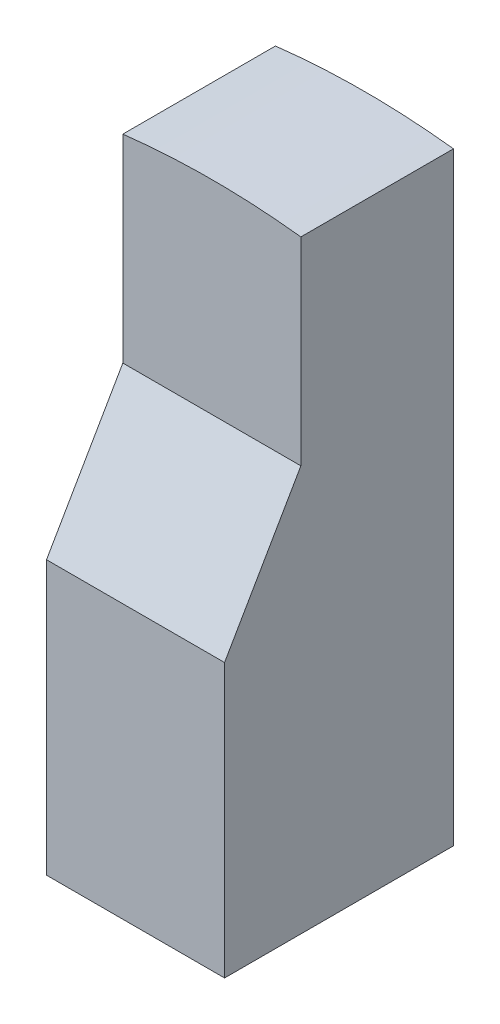
from build123d import *

# Parameters (mm, degrees)
BOSS_EXTRUDE1_DEPTH = 22.5
CUT_EXTRUDE1_DEPTH  = 36


with BuildPart() as part:
    # Sketch1 → Boss-Extrude1 (new body, symmetric)
    with BuildSketch(Plane.XY):
        with BuildLine():
            Line((-17.5, 148.975669154), (-17.5, 30.31))
            Line((-17.5, 30.31), (17.5, 30.31))
            Line((17.5, 30.31), (17.5, 148.975669154))
            ThreePointArc((17.5, 148.975669154), (0, 150), (-17.5, 148.975669154))
        make_face()
    extrude(amount=BOSS_EXTRUDE1_DEPTH, both=True)

    # Sketch2 → Cut-Extrude1 (cut, through all)
    with BuildSketch(Plane(origin=(17.5, 0, 0), x_dir=(0, 0, -1), z_dir=(1, 0, 0))):
        Polygon((-22.5, 84.019237886), (-7.5, 110), (-7.5, 150), (-22.5, 150), align=None)
    extrude(amount=-CUT_EXTRUDE1_DEPTH, mode=Mode.SUBTRACT)


solid = part.part
